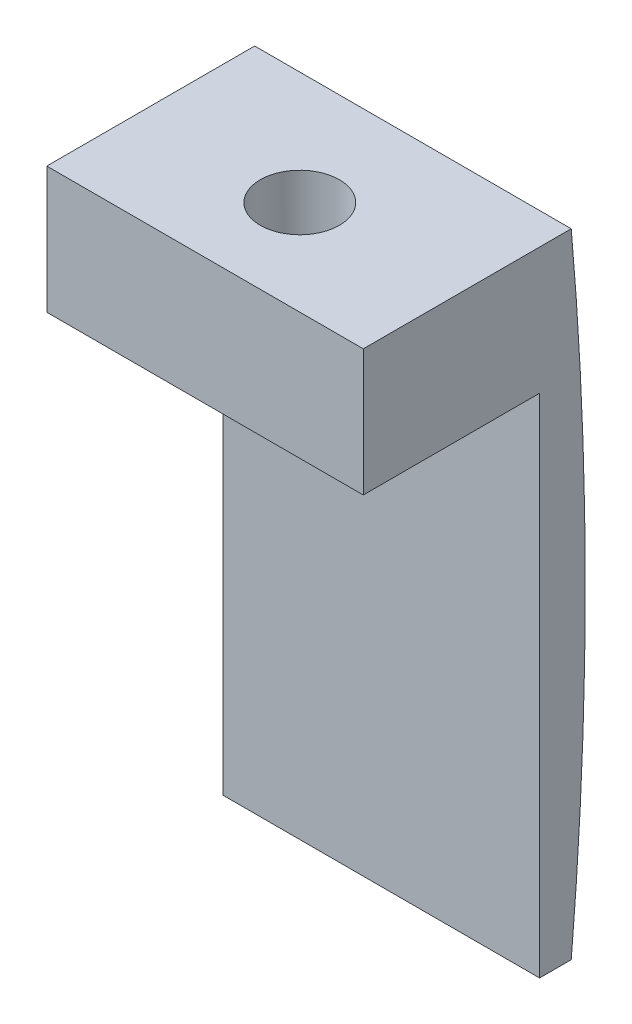
from build123d import *

# Parameters (mm, degrees)
BOSS_EXTRUDE1_DEPTH = 10
SKETCH2_R           = 1.25
CUT_EXTRUDE1_DEPTH  = 4
BOSS_EXTRUDE4_DEPTH = 10


with BuildPart() as part:
    # Sketch1 → Boss-Extrude1 (new body)
    with BuildSketch(Plane(origin=(0, 0, 0), x_dir=(0, 0, -1), z_dir=(1, 0, 0))):
        Polygon((0.362907695, 7.258153898), (-0.206723569, 7.258153898), (-6.206723569, 7.258153898), (-6.206723569, 3.258153898), (-0.637092305, 3.258153898), (-0.637092305, -12.741846102), (0.362907695, -12.741846102), align=None)
    extrude(amount=BOSS_EXTRUDE1_DEPTH)

    # Sketch2 → Cut-Extrude1 (cut)
    with BuildSketch(Plane(origin=(0, 3.258153898, 0), x_dir=(1, 0, 0), z_dir=(0, 1, 0))):
        with Locations((4.995009197, -3.206723569)):
            Circle(SKETCH2_R)
    extrude(amount=CUT_EXTRUDE1_DEPTH, mode=Mode.SUBTRACT)

    # Sketch5 → Boss-Extrude4 (add)
    with BuildSketch(Plane.ZY):
        with BuildLine():
            Line((-0.362907695, -12.741846102), (-0.362907695, 7.258153898))
            ThreePointArc((-0.362907695, 7.258153898), (-0.805423884, -2.741846102), (-0.362907695, -12.741846102))
        make_face()
    extrude(amount=-BOSS_EXTRUDE4_DEPTH)


solid = part.part
